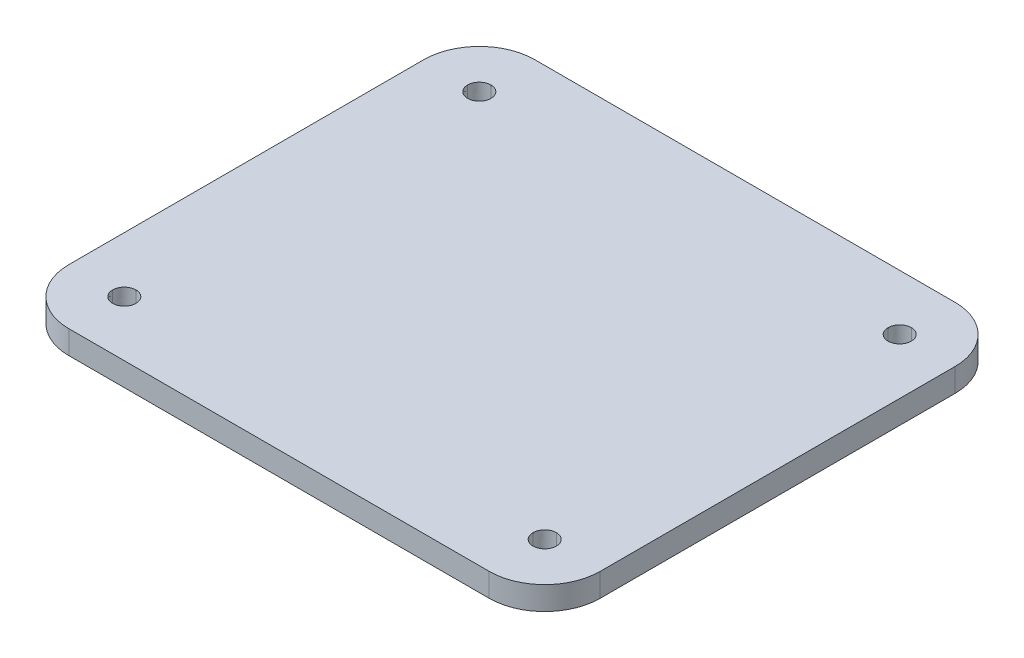
from build123d import *

# Parameters (mm, degrees)
BOSS_EXTRUDE1_DEPTH = 3.175


with BuildPart() as part:
    # Sketch1 → Boss-Extrude1 (new body)
    with BuildSketch(Plane(origin=(0, 0, 0), x_dir=(1, 0, 0), z_dir=(0, 1, 0))):
        with BuildLine():
            Line((-92.0838, 72.2973), (-34.9338, 72.2973))
            ThreePointArc((-34.9338, 72.2973), (-29.60221487, 74.50571487), (-27.3938, 79.8373))
            Line((-27.3938, 79.8373), (-27.3938, 128.0973))
            ThreePointArc((-27.3938, 128.0973), (-29.60221487, 133.42888513), (-34.9338, 135.6373))
            Line((-34.9338, 135.6373), (-92.0838, 135.6373))
            ThreePointArc((-92.0838, 135.6373), (-97.41538513, 133.42888513), (-99.6238, 128.0973))
            Line((-99.6238, 128.0973), (-99.6238, 79.8373))
            ThreePointArc((-99.6238, 79.8373), (-97.41538513, 74.50571487), (-92.0838, 72.2973))
        make_face()
        with BuildLine():
            add(Edge.make_bspline(
                [(-33.3463, 79.8373), (-33.3463, 80.7141), (-34.057, 81.4248), (-34.9338, 81.4248)],
                knots=[0, 0, 0, 0, 0.2, 0.2, 0.2, 0.2], degree=3))
            add(Edge.make_bspline(
                [(-34.9338, 81.4248), (-35.8106, 81.4248), (-36.5213, 80.7141), (-36.5213, 79.8373)],
                knots=[0.2, 0.2, 0.2, 0.2, 0.4, 0.4, 0.4, 0.4], degree=3))
            add(Edge.make_bspline(
                [(-36.5213, 79.8373), (-36.5213, 78.9605), (-35.8106, 78.2498), (-34.9338, 78.2498)],
                knots=[0.4, 0.4, 0.4, 0.4, 0.6, 0.6, 0.6, 0.6], degree=3))
            add(Edge.make_bspline(
                [(-34.9338, 78.2498), (-34.057, 78.2498), (-33.3463, 78.9605), (-33.3463, 79.8373)],
                knots=[0.6, 0.6, 0.6, 0.6, 1, 1, 1, 1], degree=3))
        make_face(mode=Mode.SUBTRACT)
        with BuildLine():
            add(Edge.make_bspline(
                [(-33.3463, 128.0973), (-33.3463, 128.9741), (-34.057, 129.6848), (-34.9338, 129.6848)],
                knots=[0, 0, 0, 0, 0.2, 0.2, 0.2, 0.2], degree=3))
            add(Edge.make_bspline(
                [(-34.9338, 129.6848), (-35.8106, 129.6848), (-36.5213, 128.9741), (-36.5213, 128.0973)],
                knots=[0.2, 0.2, 0.2, 0.2, 0.4, 0.4, 0.4, 0.4], degree=3))
            add(Edge.make_bspline(
                [(-36.5213, 128.0973), (-36.5213, 127.2205), (-35.8106, 126.5098), (-34.9338, 126.5098)],
                knots=[0.4, 0.4, 0.4, 0.4, 0.6, 0.6, 0.6, 0.6], degree=3))
            add(Edge.make_bspline(
                [(-34.9338, 126.5098), (-34.057, 126.5098), (-33.3463, 127.2205), (-33.3463, 128.0973)],
                knots=[0.6, 0.6, 0.6, 0.6, 1, 1, 1, 1], degree=3))
        make_face(mode=Mode.SUBTRACT)
        with BuildLine():
            add(Edge.make_bspline(
                [(-90.4963, 128.0973), (-90.4963, 128.9741), (-91.207, 129.6848), (-92.0838, 129.6848)],
                knots=[0, 0, 0, 0, 0.2, 0.2, 0.2, 0.2], degree=3))
            add(Edge.make_bspline(
                [(-92.0838, 129.6848), (-92.9606, 129.6848), (-93.6713, 128.9741), (-93.6713, 128.0973)],
                knots=[0.2, 0.2, 0.2, 0.2, 0.4, 0.4, 0.4, 0.4], degree=3))
            add(Edge.make_bspline(
                [(-93.6713, 128.0973), (-93.6713, 127.2205), (-92.9606, 126.5098), (-92.0838, 126.5098)],
                knots=[0.4, 0.4, 0.4, 0.4, 0.6, 0.6, 0.6, 0.6], degree=3))
            add(Edge.make_bspline(
                [(-92.0838, 126.5098), (-91.207, 126.5098), (-90.4963, 127.2205), (-90.4963, 128.0973)],
                knots=[0.6, 0.6, 0.6, 0.6, 1, 1, 1, 1], degree=3))
        make_face(mode=Mode.SUBTRACT)
        with BuildLine():
            add(Edge.make_bspline(
                [(-90.4963, 79.8373), (-90.4963, 80.7141), (-91.207, 81.4248), (-92.0838, 81.4248)],
                knots=[0, 0, 0, 0, 0.2, 0.2, 0.2, 0.2], degree=3))
            add(Edge.make_bspline(
                [(-92.0838, 81.4248), (-92.9606, 81.4248), (-93.6713, 80.7141), (-93.6713, 79.8373)],
                knots=[0.2, 0.2, 0.2, 0.2, 0.4, 0.4, 0.4, 0.4], degree=3))
            add(Edge.make_bspline(
                [(-93.6713, 79.8373), (-93.6713, 78.9605), (-92.9606, 78.2498), (-92.0838, 78.2498)],
                knots=[0.4, 0.4, 0.4, 0.4, 0.6, 0.6, 0.6, 0.6], degree=3))
            add(Edge.make_bspline(
                [(-92.0838, 78.2498), (-91.207, 78.2498), (-90.4963, 78.9605), (-90.4963, 79.8373)],
                knots=[0.6, 0.6, 0.6, 0.6, 1, 1, 1, 1], degree=3))
        make_face(mode=Mode.SUBTRACT)
    extrude(amount=BOSS_EXTRUDE1_DEPTH)


solid = part.part
